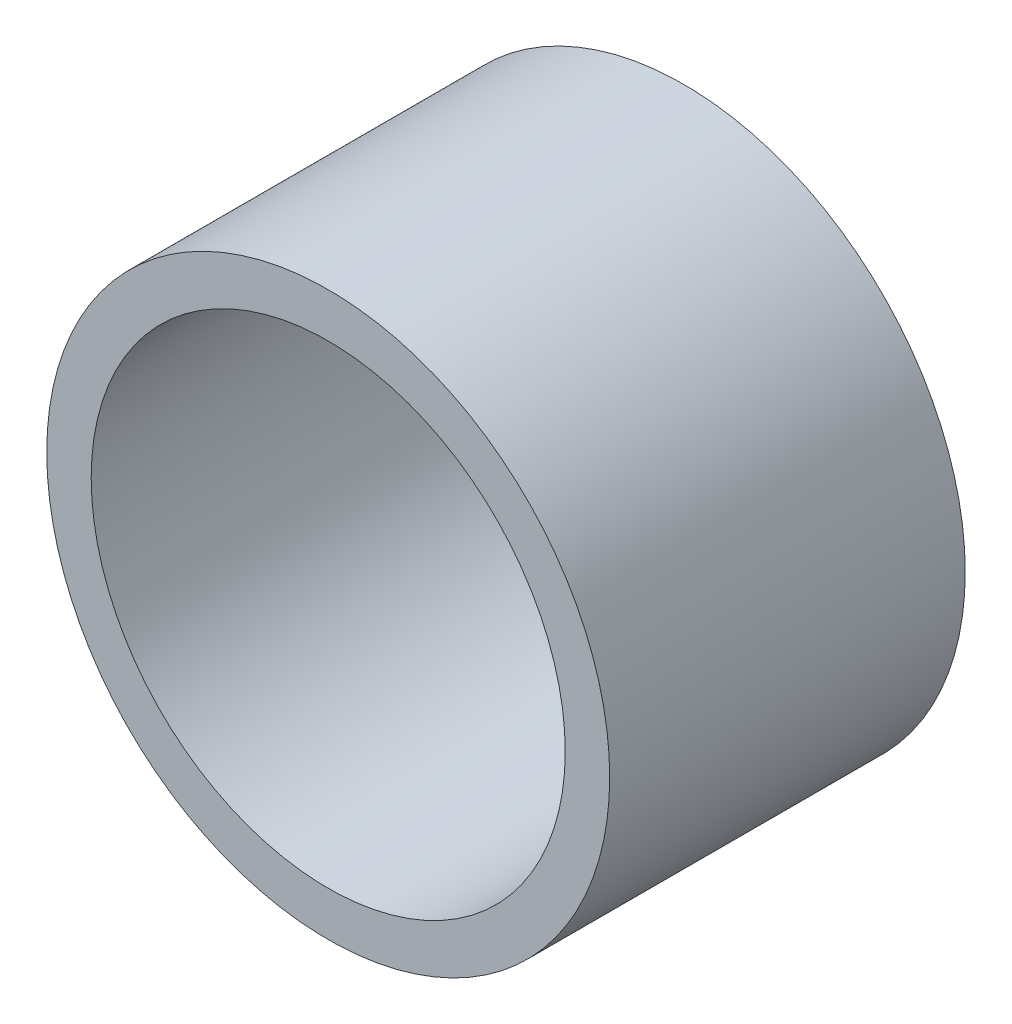
from build123d import *

# Parameters (mm, degrees)
SKETCH1_R      = 30.1625
SKETCH1_R_2    = 25.4
EXTRUDE1_DEPTH = 19.05


with BuildPart() as part:
    # Sketch1 → Extrude1 (new body, symmetric)
    with BuildSketch(Plane.XY):
        Circle(SKETCH1_R)
        Circle(SKETCH1_R_2, mode=Mode.SUBTRACT)
    extrude(amount=EXTRUDE1_DEPTH, both=True)


solid = part.part
